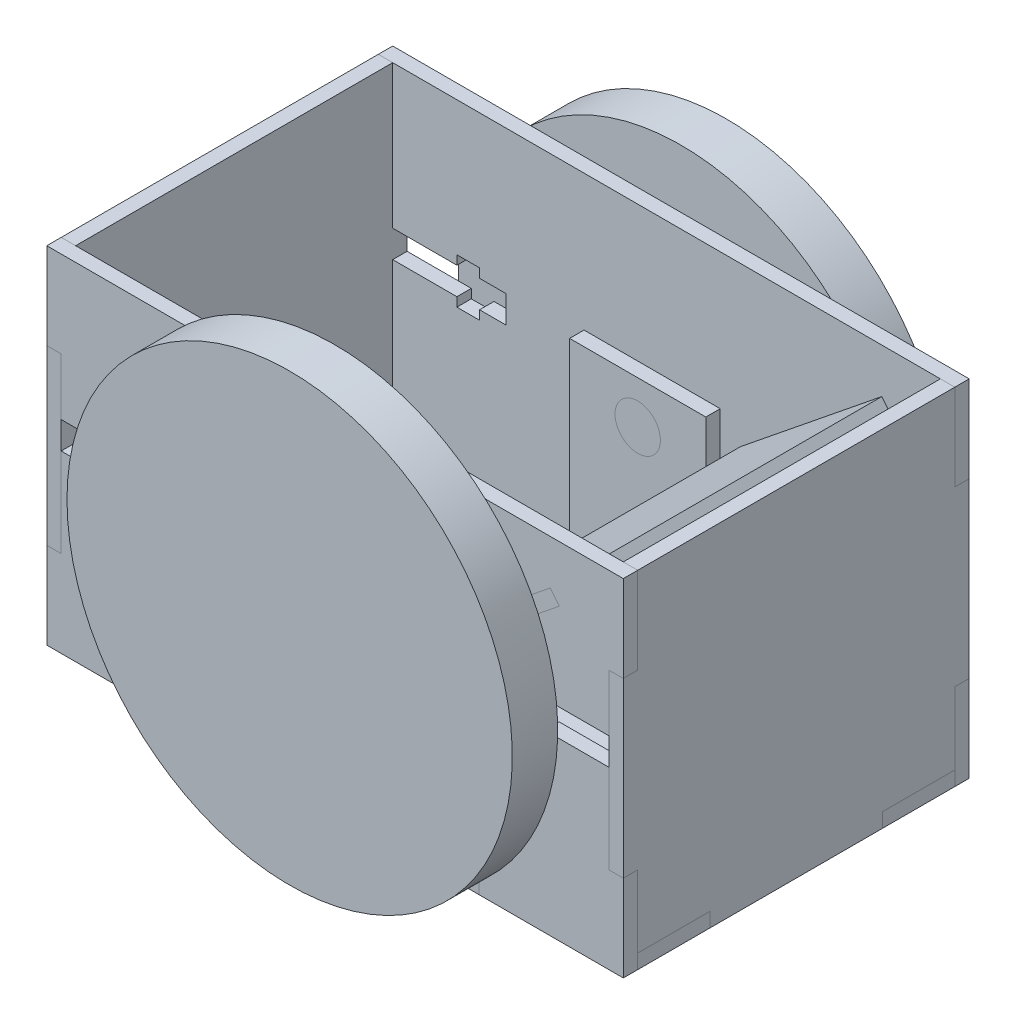
from build123d import *

# Parameters (mm, degrees)
SKETCH1_W            = 30
SKETCH1_H            = 3.175
BOSS_EXTRUDE1_DEPTH  = 3.175
SKETCH2_R            = 5
BOSS_EXTRUDE2_DEPTH  = 3.175
SKETCH3_R            = 5
BOSS_EXTRUDE4_DEPTH  = 3.175
BOSS_EXTRUDE5_DEPTH  = 3.175
BOSS_EXTRUDE6_DEPTH  = 3.175
SKETCH6_W            = 40
SKETCH6_H            = 76.2
BOSS_EXTRUDE7_DEPTH  = 3.175
SKETCH7_W            = 30
SKETCH7_H            = 49.433569184
SKETCH7_R            = 5
SKETCH7_W_2          = 48.224452428
SKETCH7_H_2          = 3.426933256
BOSS_EXTRUDE8_DEPTH  = 3.175
SKETCH8_R            = 5
BOSS_EXTRUDE9_DEPTH  = 3.175
BOSS_EXTRUDE10_DEPTH = 14


with BuildPart() as part:
    # Sketch1 → Boss-Extrude1 (new body)
    with BuildSketch(Plane(origin=(0, 0, 0), x_dir=(1, 0, 0), z_dir=(0, 1, 0))):
        Polygon((-31.75, -34.925), (-31.75, -38.1), (31.75, -38.1), (31.75, -34.925), (40.333333333, -34.925), (40.333333333, -26.760753325), (37.333333333, -26.760753325), (37.333333333, -22.760753325), (40.333333333, -22.760753325), (40.333333333, -17.014405062), (44.333333333, -17.014405062), (44.333333333, -22.760753325), (47.333333333, -22.760753325), (47.333333333, -26.760753325), (44.333333333, -26.760753325), (44.333333333, -34.925), (63.5, -34.925), (63.5, -19.05), (60.325, -19.05), (60.325, 19.05), (63.5, 19.05), (63.5, 34.925), (44.333333333, 34.925), (44.333333333, 26.760753325), (47.333333333, 26.760753325), (47.333333333, 22.760753325), (44.333333333, 22.760753325), (44.333333333, 17.014405062), (40.333333333, 17.014405062), (40.333333333, 22.760753325), (37.333333333, 22.760753325), (37.333333333, 26.760753325), (40.333333333, 26.760753325), (40.333333333, 34.925), (31.75, 34.925), (31.75, 38.1), (-31.75, 38.1), (-31.75, 34.925), (-40.333333333, 34.925), (-40.333333333, 26.760753325), (-37.333333333, 26.760753325), (-37.333333333, 22.760753325), (-40.333333333, 22.760753325), (-40.333333333, 17.014405062), (-44.333333333, 17.014405062), (-44.333333333, 22.760753325), (-47.333333333, 22.760753325), (-47.333333333, 26.760753325), (-44.333333333, 26.760753325), (-44.333333333, 34.925), (-63.5, 34.925), (-63.5, 19.05), (-60.325, 19.05), (-60.325, -19.05), (-63.5, -19.05), (-63.5, -34.925), (-44.333333333, -34.925), (-44.333333333, -26.760753325), (-47.333333333, -26.760753325), (-47.333333333, -22.760753325), (-44.333333333, -22.760753325), (-44.333333333, -17.014405062), (-40.333333333, -17.014405062), (-40.333333333, -22.760753325), (-37.333333333, -22.760753325), (-37.333333333, -26.760753325), (-40.333333333, -26.760753325), (-40.333333333, -34.925), align=None)
        with Locations((0, -30.1625)):
            Rectangle(SKETCH1_W, SKETCH1_H, mode=Mode.SUBTRACT)
        Polygon((-53.5, -1.5875), (-53.5, 1.5875), (-45.0875, 1.5875), (-45.0875, 10), (-41.9125, 10), (-41.9125, 1.5875), (-33.5, 1.5875), (-33.5, -1.5875), (-41.9125, -1.5875), (-41.9125, -10), (-45.0875, -10), (-45.0875, -1.5875), align=None, mode=Mode.SUBTRACT)
        with Locations((0, 30.1625)):
            Rectangle(SKETCH1_W, SKETCH1_H, mode=Mode.SUBTRACT)
    extrude(amount=BOSS_EXTRUDE1_DEPTH)


with BuildPart() as body_2:
    # Sketch2 → Boss-Extrude2 (new body)
    with BuildSketch(Plane.XY.offset(38.1)):
        Polygon((-63.5, 19.05), (-63.5, 0), (-31.75, 0), (-31.75, 3.175), (-3, 3.175), (-3, 17.31504408), (-5, 17.31504408), (-5, 22.31504408), (-3, 22.31504408), (-3, 28.175), (3, 28.175), (3, 22.31504408), (5, 22.31504408), (5, 17.31504408), (3, 17.31504408), (3, 3.175), (31.75, 3.175), (31.75, 0), (63.5, 0), (63.5, 19.05), (60.325, 19.05), (60.325, 38.622238448), (46.18495592, 38.622238448), (46.18495592, 36.622238448), (41.18495592, 36.622238448), (41.18495592, 38.622238448), (35.325, 38.622238448), (35.325, 44.622238448), (41.18495592, 44.622238448), (41.18495592, 46.622238448), (46.18495592, 46.622238448), (46.18495592, 44.622238448), (60.325, 44.622238448), (60.325, 57.15), (63.5, 57.15), (63.5, 76.2), (-63.5, 76.2), (-63.5, 57.15), (-60.325, 57.15), (-60.325, 44.622238448), (-46.18495592, 44.622238448), (-46.18495592, 46.622238448), (-41.18495592, 46.622238448), (-41.18495592, 44.622238448), (-35.325, 44.622238448), (-35.325, 38.622238448), (-41.18495592, 38.622238448), (-41.18495592, 36.622238448), (-46.18495592, 36.622238448), (-46.18495592, 38.622238448), (-60.325, 38.622238448), (-60.325, 19.05), align=None)
        with Locations((0, 40)):
            Circle(SKETCH2_R, mode=Mode.SUBTRACT)
        Polygon((47.424356652, 66.371956869), (49.418136774, 63.901032786), (18.288384546, 38.782543057), (16.294604424, 41.25346714), align=None, mode=Mode.SUBTRACT)
    extrude(amount=-BOSS_EXTRUDE2_DEPTH)


with BuildPart() as body_3:
    # Sketch3 → Boss-Extrude4 (new body)
    with BuildSketch(Plane(origin=(0, 0, -38.1), x_dir=(-1, 0, 0), z_dir=(0, 0, -1))):
        Polygon((-3, 28.175), (3, 28.175), (3, 22.31504408), (5, 22.31504408), (5, 17.31504408), (3, 17.31504408), (3, 3.175), (31.75, 3.175), (31.75, 0), (63.5, 0), (63.5, 19.05), (60.325, 19.05), (60.325, 38.622238448), (46.18495592, 38.622238448), (46.18495592, 36.622238448), (41.18495592, 36.622238448), (41.18495592, 38.622238448), (35.325, 38.622238448), (35.325, 44.622238448), (41.18495592, 44.622238448), (41.18495592, 46.622238448), (46.18495592, 46.622238448), (46.18495592, 44.622238448), (60.325, 44.622238448), (60.325, 57.15), (63.5, 57.15), (63.5, 76.2), (-63.5, 76.2), (-63.5, 57.15), (-60.325, 57.15), (-60.325, 44.622238448), (-46.18495592, 44.622238448), (-46.18495592, 46.622238448), (-41.18495592, 46.622238448), (-41.18495592, 44.622238448), (-35.325, 44.622238448), (-35.325, 38.622238448), (-41.18495592, 38.622238448), (-41.18495592, 36.622238448), (-46.18495592, 36.622238448), (-46.18495592, 38.622238448), (-60.325, 38.622238448), (-60.325, 19.05), (-63.5, 19.05), (-63.5, 0), (-31.75, 0), (-31.75, 3.175), (-3, 3.175), (-3, 17.31504408), (-5, 17.31504408), (-5, 22.31504408), (-3, 22.31504408), align=None)
        with Locations((0, 40)):
            Circle(SKETCH3_R, mode=Mode.SUBTRACT)
        Polygon((-47.424356652, 66.371956869), (-49.418136774, 63.901032786), (-18.288384546, 38.782543057), (-16.294604424, 41.25346714), align=None, mode=Mode.SUBTRACT)
    extrude(amount=-BOSS_EXTRUDE4_DEPTH)


with BuildPart() as body_4:
    # Sketch4 → Boss-Extrude5 (new body)
    with BuildSketch(Plane.ZY.offset(63.5)):
        Polygon((38.1, 44.622238448), (38.1, 57.15), (34.925, 57.15), (34.925, 76.2), (-34.925, 76.2), (-34.925, 57.15), (-38.1, 57.15), (-38.1, 44.622238448), (-38.1, 38.622238448), (-38.1, 19.05), (-34.925, 19.05), (-34.925, 3.175), (-19.05, 3.175), (-19.05, 0), (19.05, 0), (19.05, 3.175), (34.925, 3.175), (34.925, 19.05), (38.1, 19.05), (38.1, 38.622238448), align=None)
    extrude(amount=-BOSS_EXTRUDE5_DEPTH)


with BuildPart() as body_5:
    # Sketch5 → Boss-Extrude6 (new body)
    with BuildSketch(Plane(origin=(63.5, 0, 0), x_dir=(0, 0, -1), z_dir=(1, 0, 0))):
        Polygon((38.1, 57.15), (34.925, 57.15), (34.925, 76.2), (-34.925, 76.2), (-34.925, 57.15), (-38.1, 57.15), (-38.1, 19.05), (-34.925, 19.05), (-34.925, 3.175), (-19.05, 3.175), (-19.05, 0), (19.05, 0), (19.05, 3.175), (34.925, 3.175), (34.925, 19.05), (38.1, 19.05), align=None)
    extrude(amount=-BOSS_EXTRUDE6_DEPTH)


with BuildPart() as body_6:
    # Sketch6 → Boss-Extrude7 (new body)
    with BuildSketch(Plane(origin=(-11.74154943, 14.551492883, 0), x_dir=(0.778243806, 0.627962243, 0), z_dir=(-0.627962243, 0.778243806, 0))):
        with Locations((58.586794725, 0)):
            Rectangle(SKETCH6_W, SKETCH6_H)
    extrude(amount=BOSS_EXTRUDE7_DEPTH)


with BuildPart() as body_7:
    # Sketch7 → Boss-Extrude8 (new body)
    with BuildSketch(Plane(origin=(0, 0, 31.75), x_dir=(-1, 0, 0), z_dir=(0, 0, -1))):
        with Locations((0, 24.716784592)):
            Rectangle(SKETCH7_W, SKETCH7_H)
        with Locations((0, 40)):
            Circle(SKETCH7_R, mode=Mode.SUBTRACT)
        with Locations((0, 4.888466628)):
            Rectangle(SKETCH7_W_2, SKETCH7_H_2)
    extrude(amount=BOSS_EXTRUDE8_DEPTH)


with BuildPart() as body_8:
    # Sketch8 → Boss-Extrude9 (new body)
    with BuildSketch(Plane.XY.offset(-31.75)):
        Polygon((15, 6.601933256), (15, 49.433569184), (-15, 49.433569184), (-15, 6.601933256), (-24.112226214, 6.601933256), (-24.112226214, 3.175), (-15, 3.175), (-15, 0), (15, 0), (15, 3.175), (24.112226214, 3.175), (24.112226214, 6.601933256), align=None)
        with Locations((0, 40)):
            Circle(SKETCH8_R, mode=Mode.SUBTRACT)
    extrude(amount=BOSS_EXTRUDE9_DEPTH)


with BuildPart() as body_9:
    # Sketch10 → Revolve2 (revolve)
    with BuildSketch(Plane(origin=(0, 0, 0), x_dir=(0, 0, -1), z_dir=(1, 0, 0))):
        Polygon((38.1, 40), (28.575, 40), (28.575, 35), (38.1, 35), (38.1, -9.049751257), (48.1, -9.049751257), (48.1, 40), align=None)
    revolve(axis=Axis((0, 40, -48.1), (0, 0, 1)))


with BuildPart() as body_10:
    # Sketch11 → Boss-Extrude10 (new body)
    with BuildSketch(Plane(origin=(0, 3.175, 0), x_dir=(1, 0, 0), z_dir=(0, 1, 0))):
        Polygon((-45.0875, 10), (-41.9125, 10), (-41.9125, 1.5875), (-33.5, 1.5875), (-33.5, -1.5875), (-41.9125, -1.5875), (-41.9125, -10), (-45.0875, -10), (-45.0875, -1.5875), (-53.5, -1.5875), (-53.5, 1.5875), (-45.0875, 1.5875), align=None)
    extrude(amount=-BOSS_EXTRUDE10_DEPTH)

    # Sketch13 → Cut-Revolve2 (revolve, cut)
    with BuildSketch(Plane(origin=(-43.5, 0, 0), x_dir=(0, 0, -1), z_dir=(1, 0, 0))):
        with BuildLine():
            ThreePointArc((10, -5.694295287), (5.602808658, -9.496493948), (-0.056605155, -10.824289728))
            Line((-0.056605155, -10.824289728), (-0.056605155, -13.438962469))
            Line((-0.056605155, -13.438962469), (11.635200727, -13.438962469))
            Line((11.635200727, -13.438962469), (11.635200727, -5.694295287))
            Line((11.635200727, -5.694295287), (10, -5.694295287))
        make_face()
    revolve(axis=Axis((-43.5, -10.824289728, 0.056605155), (0, -1, 0)), mode=Mode.SUBTRACT)


with BuildPart() as body_11:
    # Mirror5: mirrored copy
    add(body_9.part.mirror(Plane.XY))


solid = Compound([part.part, body_2.part, body_3.part, body_4.part, body_5.part, body_6.part, body_7.part, body_8.part, body_9.part, body_10.part, body_11.part])
